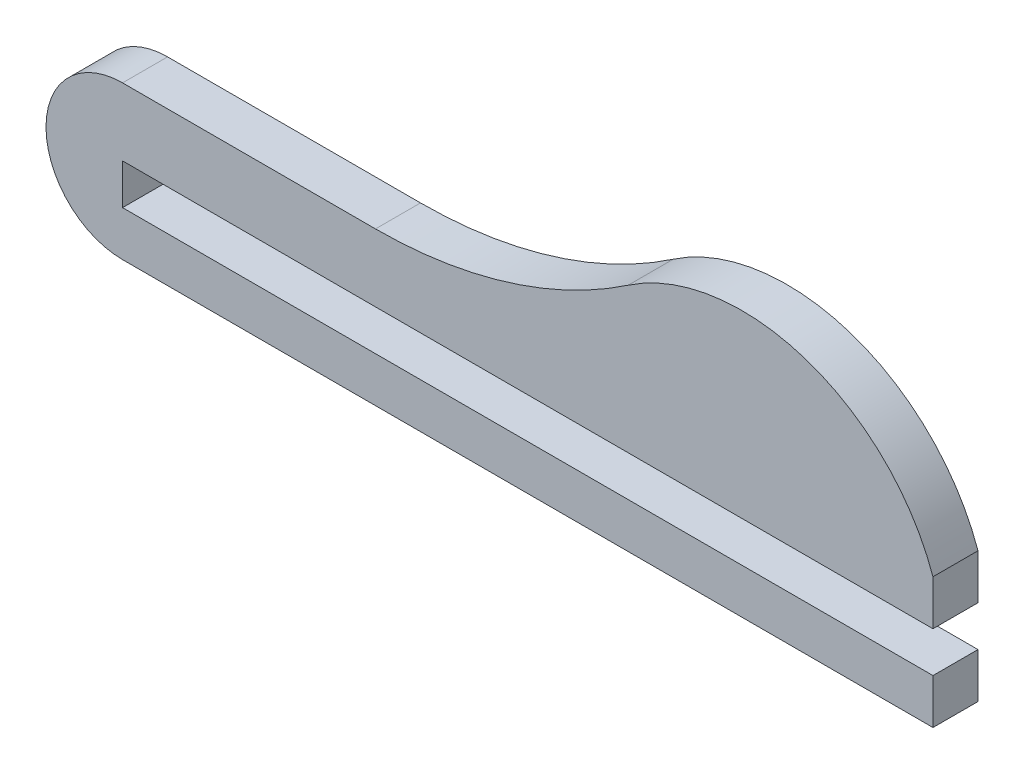
from build123d import *

# Parameters (mm, degrees)
SALIENTE_EXTRUIR1_DEPTH = 2


with BuildPart() as part:
    # Croquis1 → Saliente-Extruir1 (new body)
    with BuildSketch(Plane.XY):
        with BuildLine():
            Line((36, 0), (0, 0))
            Line((0, 0), (0, -1.8))
            Line((0, -1.8), (36, -1.8))
            Line((36, -1.8), (36, -3.8))
            Line((36, -3.8), (0, -3.8))
            ThreePointArc((0, -3.8), (-3.4, -0.4), (0, 3))
            Line((0, 3), (11.23589803, 3))
            ThreePointArc((11.23589803, 3), (17.108100225, 3.881494792), (22.462670855, 6.448275862))
            ThreePointArc((22.462670855, 6.448275862), (30.324267127, 7.550230244), (36, 2))
            Line((36, 2), (36, 0))
        make_face()
    extrude(amount=SALIENTE_EXTRUIR1_DEPTH)


solid = part.part
